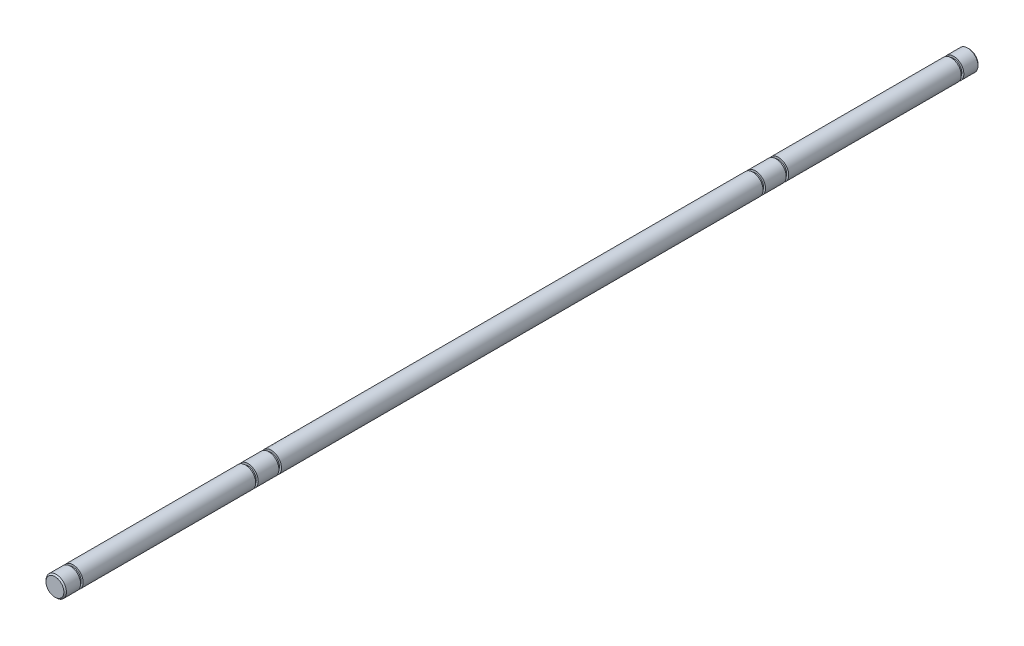
from build123d import *

# Parameters (mm, degrees)
CROQUIS1_R              = 3.99
SALIENTE_EXTRUIR1_DEPTH = 355
CROQUIS2_W              = 1
CROQUIS2_H              = 0.8
CROQUIS5_R              = 3.99
CROQUIS5_R_2            = 3.96875
CORTAR_EXTRUIR1_DEPTH   = 84
CROQUIS6_R              = 3.99
CROQUIS6_R_2            = 3.97
CORTAR_EXTRUIR2_DEPTH   = 84
CHAFL_N1_SIZE           = 0.5


with BuildPart() as part:
    # Croquis1 → Saliente-Extruir1 (new body)
    with BuildSketch(Plane.XY):
        Circle(CROQUIS1_R)
    extrude(amount=SALIENTE_EXTRUIR1_DEPTH)

    # Croquis2 → Cortar-Revolución1 (revolve, cut)
    with BuildSketch(Plane(origin=(0, 0, 0), x_dir=(0, 0, -1), z_dir=(1, 0, 0))):
        with Locations((-6.5, 3.59)):
            Rectangle(CROQUIS2_W, CROQUIS2_H)
        with Locations((-74.5, 3.59)):
            Rectangle(CROQUIS2_W, CROQUIS2_H)
        with Locations((-83.5, 3.59)):
            Rectangle(CROQUIS2_W, CROQUIS2_H)
    cortar_revoluci_n1 = revolve(axis=Axis((0, 0, 355), (0, 0, -1)), mode=Mode.SUBTRACT)

    # Simetría1: Cortar-Revolución1 across plane
    add(cortar_revoluci_n1.mirror(Plane.XY.offset(177.5)), mode=Mode.SUBTRACT)

    # Croquis5 → Cortar-Extruir1 (cut)
    with BuildSketch(Plane.XY.offset(355)):
        Circle(CROQUIS5_R)
        Circle(CROQUIS5_R_2, mode=Mode.SUBTRACT)
    extrude(amount=-CORTAR_EXTRUIR1_DEPTH, mode=Mode.SUBTRACT)

    # Croquis6 → Cortar-Extruir2 (cut)
    with BuildSketch(Plane(origin=(0, 0, 0), x_dir=(-1, 0, 0), z_dir=(0, 0, -1))):
        Circle(CROQUIS6_R)
        Circle(CROQUIS6_R_2, mode=Mode.SUBTRACT)
    extrude(amount=-CORTAR_EXTRUIR2_DEPTH, mode=Mode.SUBTRACT)

    # Chaflán1
    chafl_n1_edges = [part.edges().sort_by_distance(p)[0] for p in [
        (-3.96875, 0, 355),
        (3.97, 0, 0),
    ]]
    chamfer(chafl_n1_edges, length=CHAFL_N1_SIZE)


solid = part.part
